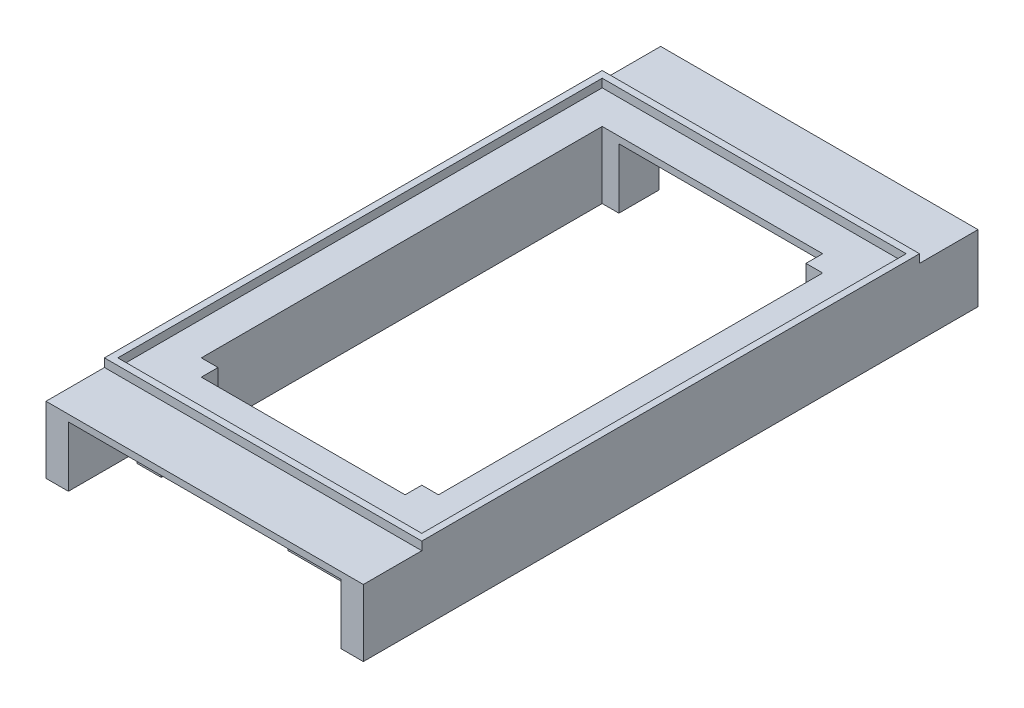
from build123d import *

# Parameters (mm, degrees)
SKETCH1_W           = 9.5
SKETCH1_H           = 16.65
BOSS_EXTRUDE1_DEPTH = 0.2
SKETCH1_3_W         = 0.5
SKETCH1_3_H         = 0.5
BOSS_EXTRUDE2_DEPTH = 2
SKETCH1_4_W         = 9.5
SKETCH1_4_H         = 14.9
SKETCH1_4_W_2       = 9.1
SKETCH1_4_H_2       = 14.5
BOSS_EXTRUDE3_DEPTH = 0.25
BOSS_EXTRUDE4_DEPTH = 2
SKETCH1_6_W         = 0.670753581
SKETCH1_6_H         = 1.75
SKETCH1_6_W_2       = 1.029246419
SKETCH1_6_H_2       = 0.5
SKETCH1_6_W_3       = 3.329246419
BOSS_EXTRUDE5_DEPTH = 2
FILLET1_R           = 0.1
BOSS_EXTRUDE6_DEPTH = 0.2
SKETCH1_10_W        = 3.329246419
SKETCH1_10_H        = 0.5
SKETCH1_10_W_2      = 0.670753581
SKETCH1_10_H_2      = 1.75
BOSS_EXTRUDE7_DEPTH = 2
CUT_EXTRUDE1_DEPTH  = 18.429429136


with BuildPart() as part:
    # Sketch1 → Boss-Extrude1 (new body)
    with BuildSketch(Plane(origin=(0, 0, 0), x_dir=(1, 0, 0), z_dir=(0, 1, 0))):
        with Locations((0, -0.875)):
            Rectangle(SKETCH1_W, SKETCH1_H)
        Polygon((-3.55, 6.25), (3.05, 6.25), (3.05, 5.75), (3.55, 5.75), (3.55, -5.75), (3.05, -5.75), (3.05, -6.25), (-3.05, -6.25), (-3.05, -5.75), (-3.55, -5.75), align=None, mode=Mode.SUBTRACT)
    extrude(amount=-BOSS_EXTRUDE1_DEPTH)

    # Sketch1_3 → Boss-Extrude2 (add)
    with BuildSketch(Plane(origin=(0, 0, 0), x_dir=(1, 0, 0), z_dir=(0, 1, 0))):
        with Locations((3.3, -6)):
            Rectangle(SKETCH1_3_W, SKETCH1_3_H)
        with Locations((3.3, 6)):
            Rectangle(SKETCH1_3_W, SKETCH1_3_H)
        with Locations((-3.3, -6)):
            Rectangle(SKETCH1_3_W, SKETCH1_3_H)
    extrude(amount=-BOSS_EXTRUDE2_DEPTH)

    # Sketch1_4 → Boss-Extrude3 (add)
    with BuildSketch(Plane(origin=(0, 0, 0), x_dir=(1, 0, 0), z_dir=(0, 1, 0))):
        Rectangle(SKETCH1_4_W, SKETCH1_4_H)
        Rectangle(SKETCH1_4_W_2, SKETCH1_4_H_2, mode=Mode.SUBTRACT)
    extrude(amount=BOSS_EXTRUDE3_DEPTH)

    # Sketch1_5 → Boss-Extrude4 (add)
    with BuildSketch(Plane(origin=(0, 0, 0), x_dir=(1, 0, 0), z_dir=(0, 1, 0))):
        Polygon((-4.75, 7.45), (-4.75, -7.45), (-3.05, -7.45), (-3.05, -6.25), (-3.55, -6.25), (-3.55, 6.25), (-3.05, 6.25), (-3.05, 7.45), align=None)
        Polygon((3.55, -6.25), (3.05, -6.25), (3.05, -6.95), (4.079246419, -6.95), (4.079246419, -7.45), (4.75, -7.45), (4.75, 7.45), (4.079246419, 7.45), (4.079246419, 6.95), (3.05, 6.95), (3.05, 6.25), (3.55, 6.25), align=None)
    extrude(amount=-BOSS_EXTRUDE4_DEPTH)

    # Sketch1_6 → Boss-Extrude5 (add)
    with BuildSketch(Plane(origin=(0, 0, 0), x_dir=(1, 0, 0), z_dir=(0, 1, 0))):
        with Locations((-4.41462321, -8.325)):
            Rectangle(SKETCH1_6_W, SKETCH1_6_H)
        with Locations((3.56462321, 7.2)):
            Rectangle(SKETCH1_6_W_2, SKETCH1_6_H_2)
        with Locations((2.41462321, -7.2)):
            Rectangle(SKETCH1_6_W_3, SKETCH1_6_H_2)
        with Locations((4.41462321, -8.325)):
            Rectangle(SKETCH1_6_W, SKETCH1_6_H)
    extrude(amount=-BOSS_EXTRUDE5_DEPTH)

    # Fillet1
    fillet1_edges = [part.edges().sort_by_distance(p)[0] for p in [
        (3.05, -1.1, 6.95),
    ]]
    fillet(fillet1_edges, radius=FILLET1_R)

    # Sketch1_9 → Boss-Extrude6 (add)
    with BuildSketch(Plane(origin=(0, 0, 0), x_dir=(1, 0, 0), z_dir=(0, 1, 0))):
        Polygon((-4.079246419, 9.2), (-4.079246419, 7.45), (-3.05, 7.45), (0, 7.45), (0.75, 7.45), (3.05, 7.45), (4.079246419, 7.45), (4.079246419, 8.7), (0.75, 8.7), (0.75, 9.2), align=None)
    extrude(amount=-BOSS_EXTRUDE6_DEPTH)

    # Sketch1_10 → Boss-Extrude7 (add)
    with BuildSketch(Plane(origin=(0, 0, 0), x_dir=(1, 0, 0), z_dir=(0, 1, 0))):
        with Locations((2.41462321, 8.95)):
            Rectangle(SKETCH1_10_W, SKETCH1_10_H)
        Polygon((4.75, 9.2), (4.079246419, 9.2), (4.079246419, 8.7), (4.079246419, 7.45), (4.75, 7.45), align=None)
        with Locations((-4.41462321, 8.325)):
            Rectangle(SKETCH1_10_W_2, SKETCH1_10_H_2)
    extrude(amount=-BOSS_EXTRUDE7_DEPTH)

    # Sketch6 → Cut-Extrude1 (cut, through all)
    with BuildSketch(Plane.XY.offset(7.45)):
        with BuildLine():
            Line((-4.079246419, -2), (-3.779246419, -2))
            Line((-3.779246419, -2), (-3.779246419, -1.8))
            ThreePointArc((-3.779246419, -1.8), (-3.808535741, -1.729289322), (-3.879246419, -1.7))
            Line((-3.879246419, -1.7), (-3.979246419, -1.7))
            ThreePointArc((-3.979246419, -1.7), (-4.049957097, -1.729289322), (-4.079246419, -1.8))
            Line((-4.079246419, -1.8), (-4.079246419, -2))
        make_face()
    cut_extrude1 = extrude(amount=-CUT_EXTRUDE1_DEPTH, mode=Mode.SUBTRACT)

    # Mirror1: Cut-Extrude1 across plane
    add(cut_extrude1.mirror(Plane(origin=(0, 0, 0), x_dir=(0, 0, 1), z_dir=(1, 0, 0))), mode=Mode.SUBTRACT)


solid = part.part
